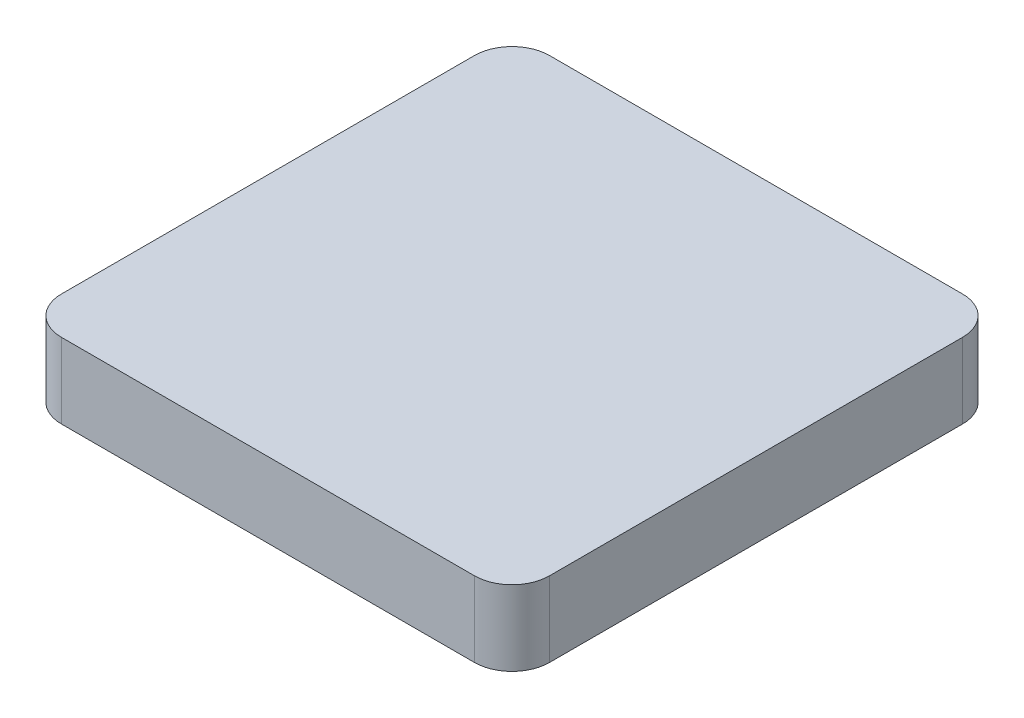
from build123d import *

# Parameters (mm, degrees)
BOSS_EXTRUDE1_DEPTH = 2


with BuildPart() as part:
    # Sketch1 → Boss-Extrude1 (new body)
    with BuildSketch(Plane(origin=(0, 0, 0), x_dir=(1, 0, 0), z_dir=(0, 1, 0))):
        with BuildLine():
            Line((5.5, -6.5), (-5.5, -6.5))
            ThreePointArc((-5.5, -6.5), (-6.207106781, -6.207106781), (-6.5, -5.5))
            Line((-6.5, -5.5), (-6.5, 5.5))
            ThreePointArc((-6.5, 5.5), (-6.207106781, 6.207106781), (-5.5, 6.5))
            Line((-5.5, 6.5), (5.5, 6.5))
            ThreePointArc((5.5, 6.5), (6.207106781, 6.207106781), (6.5, 5.5))
            Line((6.5, 5.5), (6.5, -5.5))
            ThreePointArc((6.5, -5.5), (6.207106781, -6.207106781), (5.5, -6.5))
        make_face()
    extrude(amount=BOSS_EXTRUDE1_DEPTH)


solid = part.part
